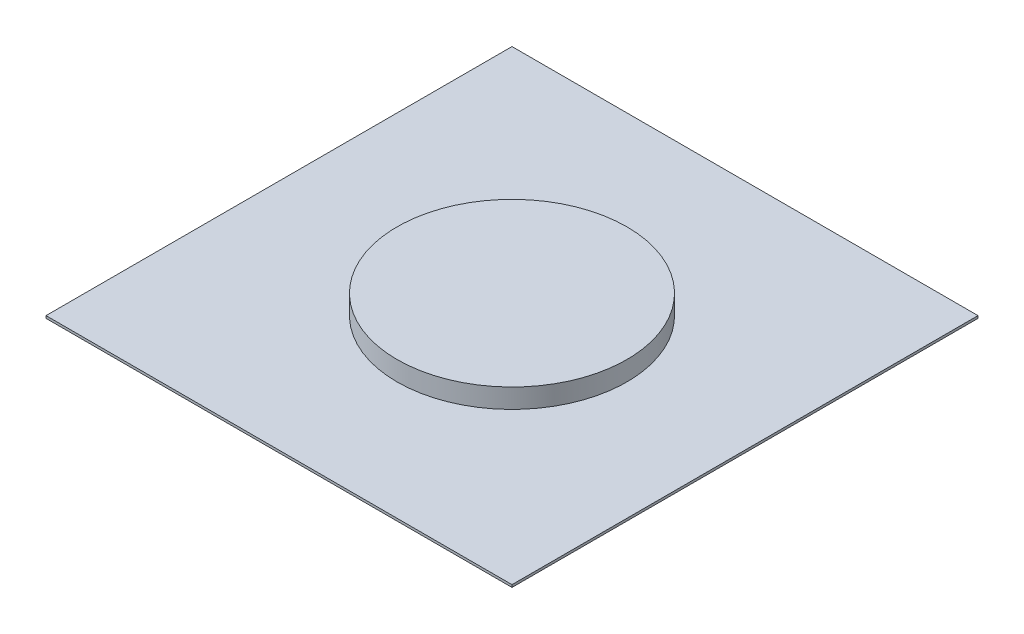
from build123d import *

# Parameters (mm, degrees)
SKETCH1_W      = 609.6
SKETCH1_H      = 609.6
EXTRUDE1_DEPTH = 3.175
SKETCH3_R      = 150.36165
EXTRUDE2_DEPTH = 25.4


with BuildPart() as part:
    # Sketch1 → Extrude1 (new body)
    with BuildSketch(Plane(origin=(0, 0, 0), x_dir=(1, 0, 0), z_dir=(0, 1, 0))):
        Rectangle(SKETCH1_W, SKETCH1_H)
    extrude(amount=-EXTRUDE1_DEPTH)


with BuildPart() as body_2:
    # sketch3 → Extrude2 (new body)
    with BuildSketch(Plane(origin=(0, 0, 0), x_dir=(-1, 0, 0), z_dir=(0, 1, 0))):
        Circle(SKETCH3_R)
    extrude(amount=EXTRUDE2_DEPTH)


solid = Compound([part.part, body_2.part])
